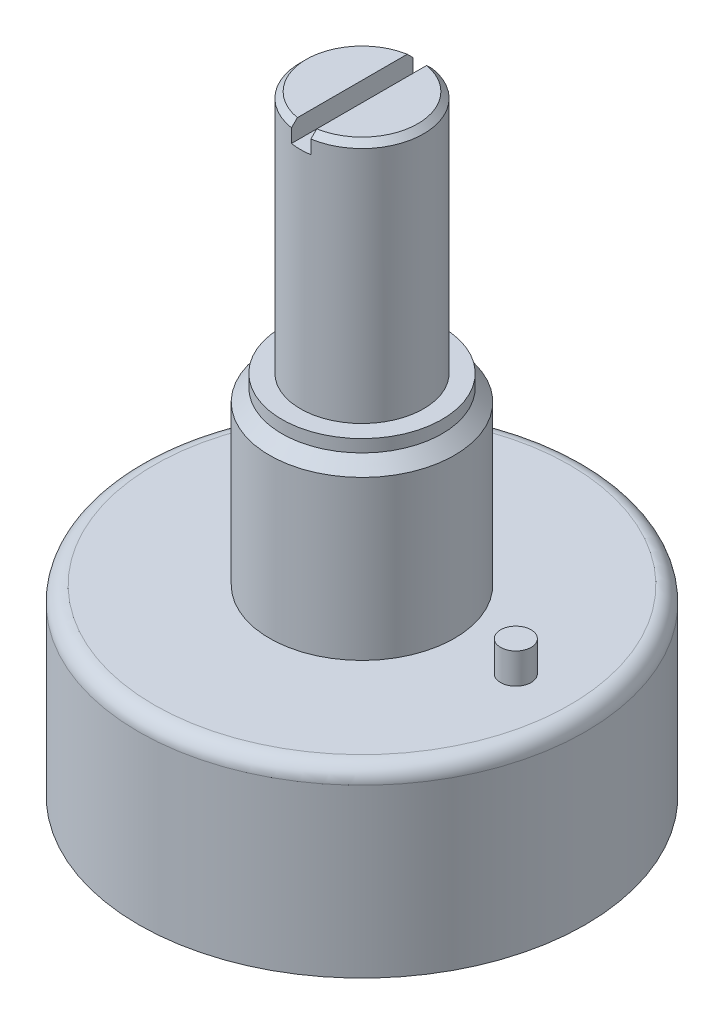
from build123d import *

# Parameters (mm, degrees)
CHAMFER1_SIZE       = 0.3
SKETCH2_W           = 1
SKETCH2_H           = 6.571948564
CUT_EXTRUDE1_DEPTH  = 1
FILLET1_R           = 0.8
SKETCH3_R           = 0.785
BOSS_EXTRUDE1_DEPTH = 1.57
SKETCH4_R           = 1
BOSS_EXTRUDE2_DEPTH = 0.6
SKETCH5_R           = 0.7
BOSS_EXTRUDE3_DEPTH = 2
SKETCH6_R           = 1
BOSS_EXTRUDE4_DEPTH = 0.6


with BuildPart() as part:
    # Sketch1 → Revolve1 (revolve)
    with BuildSketch(Plane.XY):
        Polygon((0, 0), (0, 31.4), (-3.1725, 31.4), (-3.1725, 18.84), (-4.1225, 18.84), (-4.1225, 18.2), (-4.7625, 17.56), (-4.7625, 9.4), (-11.5, 9.4), (-11.5, 0), align=None)
    revolve(axis=Axis((0, 0, 0), (0, 1, 0)))

    # Chamfer1
    chamfer1_edges = [part.edges().sort_by_distance(p)[0] for p in [
        (3.1725, 31.4, 0),
    ]]
    chamfer(chamfer1_edges, length=CHAMFER1_SIZE)

    # Sketch2 → Cut-Extrude1 (cut)
    with BuildSketch(Plane(origin=(0, 31.4, 0), x_dir=(1, 0, 0), z_dir=(0, 1, 0))):
        Rectangle(SKETCH2_W, SKETCH2_H)
    extrude(amount=-CUT_EXTRUDE1_DEPTH, mode=Mode.SUBTRACT)

    # Fillet1
    fillet1_edges = [part.edges().sort_by_distance(p)[0] for p in [
        (11.5, 9.4, 0),
    ]]
    fillet(fillet1_edges, radius=FILLET1_R)

    # Sketch3 → Boss-Extrude1 (add)
    with BuildSketch(Plane(origin=(0, 9.4, 0), x_dir=(1, 0, 0), z_dir=(0, 1, 0))):
        with Locations((7.92, 0)):
            Circle(SKETCH3_R)
    extrude(amount=BOSS_EXTRUDE1_DEPTH)

    # Sketch4 → Boss-Extrude2 (add)
    with BuildSketch(Plane.XZ):
        with Locations((4.5, 0)):
            Circle(SKETCH4_R)
        with Locations((-3.181980515, 3.181980515)):
            Circle(SKETCH4_R)
        with Locations((-3.181980515, -3.181980515)):
            Circle(SKETCH4_R)
    extrude(amount=BOSS_EXTRUDE2_DEPTH)

    # Sketch5 → Boss-Extrude3 (add)
    with BuildSketch(Plane.XZ.offset(0.6)):
        with Locations((-3.181980515, 3.181980515)):
            Circle(SKETCH5_R)
        with Locations((4.5, 0)):
            Circle(SKETCH5_R)
        with Locations((-3.181980515, -3.181980515)):
            Circle(SKETCH5_R)
    extrude(amount=BOSS_EXTRUDE3_DEPTH)

    # Sketch6 → Boss-Extrude4 (add)
    with BuildSketch(Plane.XZ.offset(2.6)):
        with Locations((-3.181980515, 3.181980515)):
            Circle(SKETCH6_R)
        with Locations((4.5, 0)):
            Circle(SKETCH6_R)
        with Locations((-3.181980515, -3.181980515)):
            Circle(SKETCH6_R)
    extrude(amount=BOSS_EXTRUDE4_DEPTH)


solid = part.part
